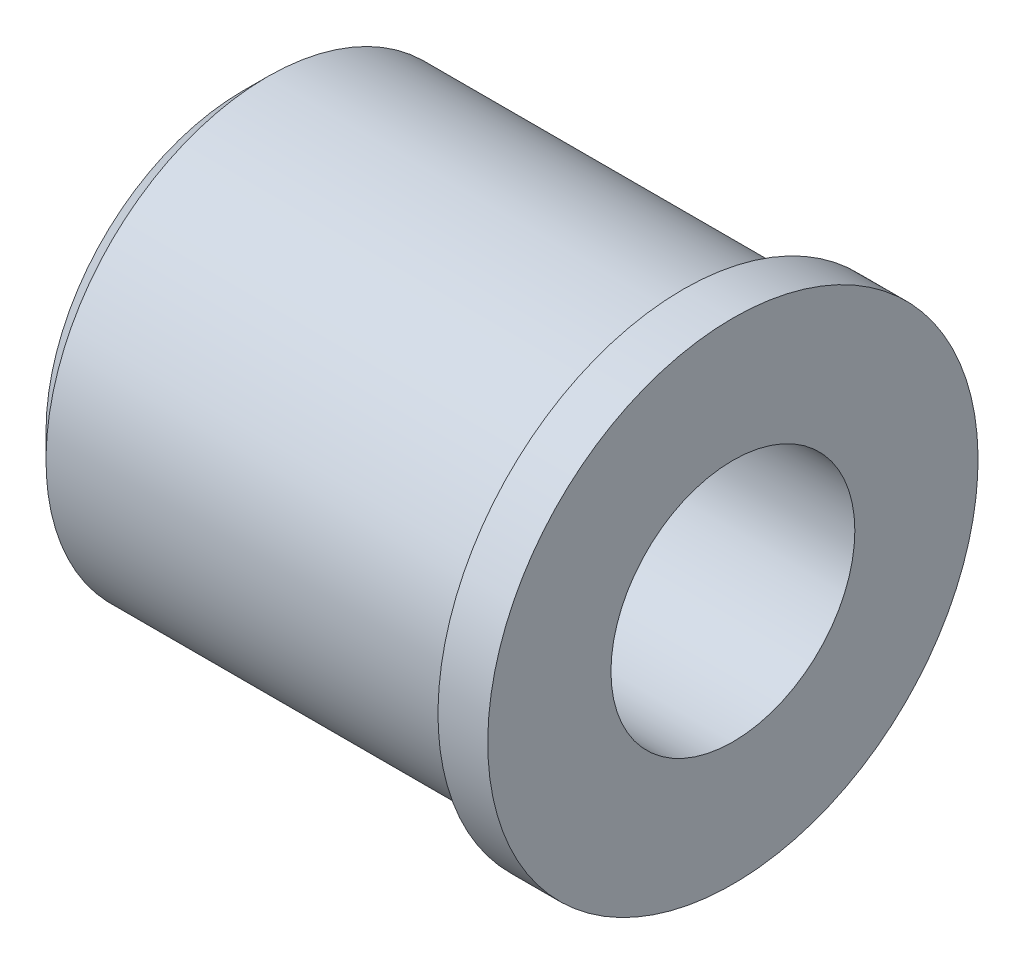
from build123d import *

# Parameters (mm, degrees)
M3X0_25_4H_TAPPED_HOLE1_D = 2.4892


with BuildPart() as part:
    # Sketch1 one side → Revolve1 (revolve)
    with BuildSketch(Plane.XY, mode=Mode.PRIVATE) as revolve1_sk:
        Polygon((-0.508, -2.5019), (0, -2.5019), (0, 0), (-5.0038, 0), (-5.0038, -2.0066), (-4.7498, -2.2606), (-0.508, -2.2606), align=None)
    revolve(revolve1_sk.sketch.rotate(Axis((0, 0, 0), (-1, 0, 0)), 180), axis=Axis((0, 0, 0), (-1, 0, 0)))  # turned: the seam where the file's is

    # M3x0.25-4h Tapped Hole1 (through all)
    with Locations(Plane.YZ):
        with Locations((0, 0)):
            Hole(M3X0_25_4H_TAPPED_HOLE1_D / 2)


solid = part.part
